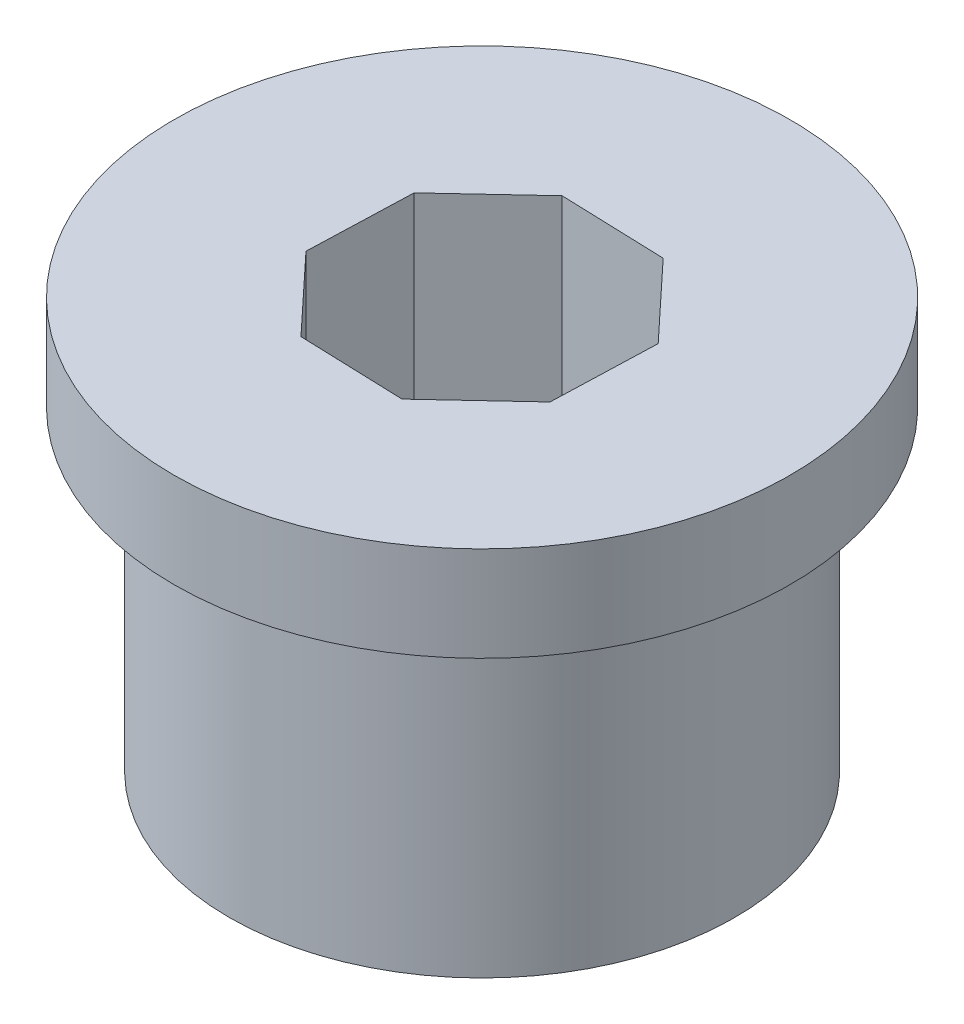
from build123d import *

# Parameters (mm, degrees)
SKETCH1_R           = 8
BOSS_EXTRUDE1_DEPTH = 10
SKETCH2_R           = 9.75
BOSS_EXTRUDE2_DEPTH = 3
CUT_EXTRUDE1_DEPTH  = 14


with BuildPart() as part:
    # Sketch1 → Boss-Extrude1 (new body)
    with BuildSketch(Plane(origin=(0, 0, 0), x_dir=(1, 0, 0), z_dir=(0, 1, 0))):
        Circle(SKETCH1_R)
    extrude(amount=BOSS_EXTRUDE1_DEPTH)

    # Sketch2 → Boss-Extrude2 (add)
    with BuildSketch(Plane(origin=(0, 10, 0), x_dir=(1, 0, 0), z_dir=(0, 1, 0))):
        Circle(SKETCH2_R)
    extrude(amount=BOSS_EXTRUDE2_DEPTH)

    # Sketch3 → Cut-Extrude1 (cut, through all)
    with BuildSketch(Plane(origin=(0, 13, 0), x_dir=(1, 0, 0), z_dir=(0, 1, 0))):
        Polygon((3.941633327, -1.791282422), (4.053783603, 1.520527707), (1.791282422, 3.941633327), (-1.520527707, 4.053783603), (-3.941633327, 1.791282422), (-4.053783603, -1.520527707), (-1.791282422, -3.941633327), (1.520527707, -4.053783603), align=None)
    extrude(amount=-CUT_EXTRUDE1_DEPTH, mode=Mode.SUBTRACT)


solid = part.part
